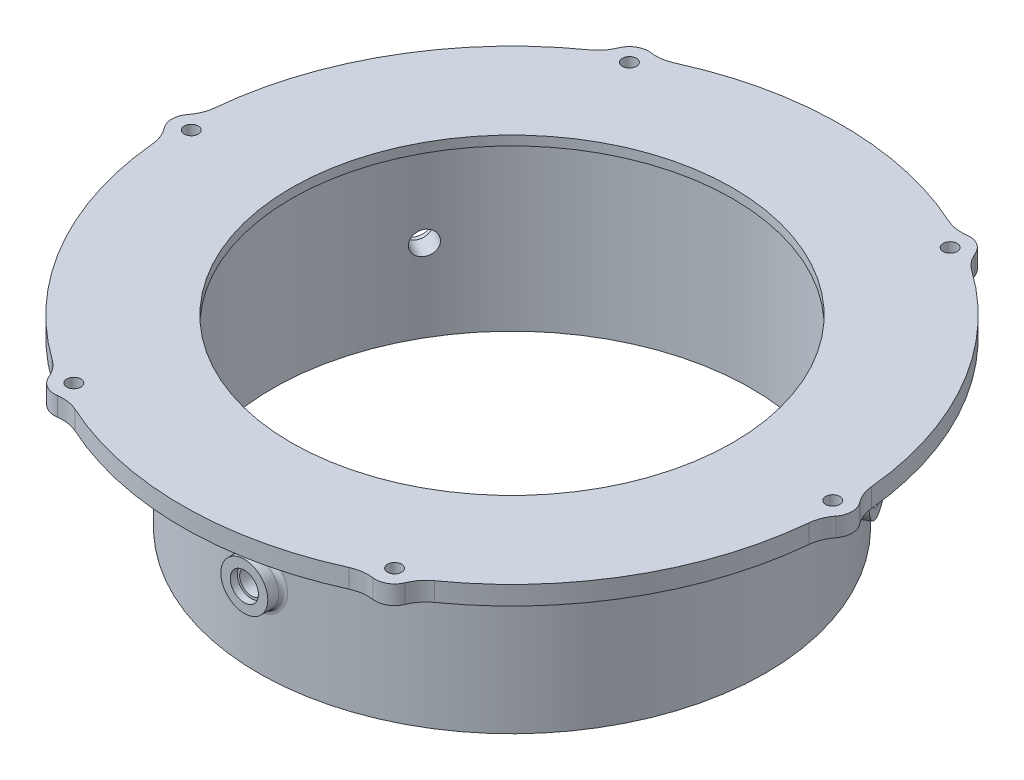
from build123d import *

# Parameters (mm, degrees)
BOSS_EXTRUDE1_START      = -3.2
SKETCH5_R                = 4.1
BOSS_EXTRUDE1_DEPTH      = 4
FILLET1_R                = 8
CIRPATTERN1_COUNT        = 6
FILLET1_OF_CIRPATTERN1_R = 8
BOSS_EXTRUDE3_START      = -0.23198
SKETCH14_R               = 5
BOSS_EXTRUDE3_DEPTH      = 3.23198
CUT_EXTRUDE11_START      = 3
SKETCH15_R               = 2.5
CUT_EXTRUDE11_DEPTH      = 6.061311
CUT_EXTRUDE12_START      = 3
SKETCH16_R               = 3
CUT_EXTRUDE12_DEPTH      = 1.5
FILLET2_R                = 1
CIRPATTERN3_COUNT        = 3
FILLET2_OF_CIRPATTERN3_R = 1


with BuildPart() as part:
    # Sketch3 → FRA400 100mm (revolve)
    with BuildSketch(Plane.XY):
        Polygon((-47, -3.2), (-70.2, -3.2), (-70.2, -7.2), (-54, -7.2), (-54, -42.2), (-51, -42.2), (-51, -5.2), (-47, -5.2), align=None)
    revolve(axis=Axis((0, 0, 0), (0, 1, 0)))

    # Sketch5 → Boss-Extrude1 (add)
    with BuildSketch(Plane(origin=(0, 0, 0), x_dir=(1, 0, 0), z_dir=(0, 1, 0)).offset(BOSS_EXTRUDE1_START)):
        with Locations((-68.3, 0)):
            Circle(SKETCH5_R)
    boss_extrude1 = extrude(amount=-BOSS_EXTRUDE1_DEPTH)

    # Fillet1
    fillet1_edges = [part.edges().sort_by_distance(p)[0] for p in [
        (-70.103367496, -5.2, -3.682100715),
        (-70.103367496, -5.2, 3.682100715),
    ]]
    fillet(fillet1_edges, radius=FILLET1_R)

    # Sketch9 → CSK for M3 Flat Head Machine Screw1 (revolve, cut)
    with BuildSketch(Plane(origin=(-68.3, -7.2, 0), x_dir=(0, 0, -1), z_dir=(1, 0, 0))):
        Polygon((0, 0), (0, 9.791290929), (1.5, 8.89), (1.5, 1.6), (3.1, 0), align=None)
    csk_for_m3_flat_head_machine_screw1 = revolve(axis=Axis((-68.3, -13.55, 0), (0, 1, 0)), mode=Mode.SUBTRACT)

    # CirPattern1: Boss-Extrude1, CSK for M3 Flat Head Machine Screw1 ×6 about axis
    cirpattern1_axis = Axis((0, 0, 0), (0, 1, 0))
    for i in range(1, CIRPATTERN1_COUNT):
        add(boss_extrude1.rotate(cirpattern1_axis, i * 360 / CIRPATTERN1_COUNT))
        add(csk_for_m3_flat_head_machine_screw1.rotate(cirpattern1_axis, i * 360 / CIRPATTERN1_COUNT), mode=Mode.SUBTRACT)

    # Fillet1 of CirPattern1
    fillet1_of_cirpattern1_edges = [part.edges().sort_by_distance(p)[0] for p in [
        (-38.240476506, -5.2, 58.870246785),
        (-31.86289099, -5.2, 62.5523475),
        (31.86289099, -5.2, 62.5523475),
        (38.240476506, -5.2, 58.870246785),
        (70.103367496, -5.2, 3.682100715),
        (70.103367496, -5.2, -3.682100715),
        (38.240476506, -5.2, -58.870246785),
        (31.86289099, -5.2, -62.5523475),
        (-31.86289099, -5.2, -62.5523475),
        (-38.240476506, -5.2, -58.870246785),
    ]]
    fillet(fillet1_of_cirpattern1_edges, radius=FILLET1_OF_CIRPATTERN1_R)

    # Sketch14 → Boss-Extrude3 (add)
    with BuildSketch(Plane.XY.offset(54).offset(BOSS_EXTRUDE3_START)):
        with Locations((0, -24.7)):
            Circle(SKETCH14_R)
    boss_extrude3 = extrude(amount=BOSS_EXTRUDE3_DEPTH)

    # Sketch15 → Cut-Extrude11 (cut)
    with BuildSketch(Plane.XY.offset(54).offset(CUT_EXTRUDE11_START)):
        with Locations((0, -24.7)):
            Circle(SKETCH15_R)
    cut_extrude11 = extrude(amount=-CUT_EXTRUDE11_DEPTH, mode=Mode.SUBTRACT)

    # Sketch16 → Cut-Extrude12 (cut)
    with BuildSketch(Plane.XY.offset(54).offset(CUT_EXTRUDE12_START)):
        with Locations((0, -24.7)):
            Circle(SKETCH16_R)
    cut_extrude12 = extrude(amount=-CUT_EXTRUDE12_DEPTH, mode=Mode.SUBTRACT)

    # Fillet2
    fillet2_edges = [part.edges().sort_by_distance(p)[0] for p in [
        (-5, -24.7, 53.768020235),
    ]]
    fillet(fillet2_edges, radius=FILLET2_R)

    # CirPattern3: Boss-Extrude3, Cut-Extrude11, Cut-Extrude12 ×3 about axis
    cirpattern3_axis = Axis((0, 0, 0), (0, 1, 0))
    for i in range(1, CIRPATTERN3_COUNT):
        add(boss_extrude3.rotate(cirpattern3_axis, i * 360 / CIRPATTERN3_COUNT))
        add(cut_extrude11.rotate(cirpattern3_axis, i * 360 / CIRPATTERN3_COUNT), mode=Mode.SUBTRACT)
        add(cut_extrude12.rotate(cirpattern3_axis, i * 360 / CIRPATTERN3_COUNT), mode=Mode.SUBTRACT)

    # Fillet2 of CirPattern3
    fillet2_of_cirpattern3_edges = [part.edges().sort_by_distance(p)[0] for p in [
        (49.064471435, -24.7, -22.553883099),
        (-44.064471435, -24.7, -31.214137136),
    ]]
    fillet(fillet2_of_cirpattern3_edges, radius=FILLET2_OF_CIRPATTERN3_R)


solid = part.part
